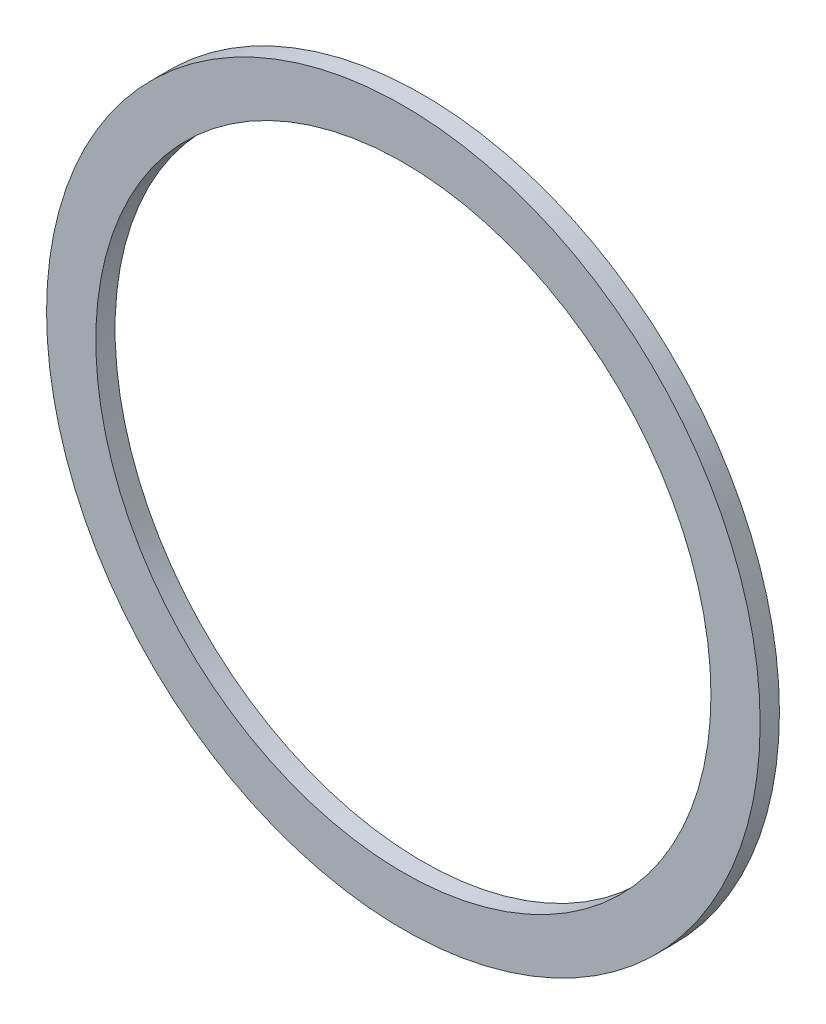
from build123d import *

# Parameters (mm, degrees)
SKETCH1_R           = 87
SKETCH1_R_2         = 75
BOSS_EXTRUDE1_DEPTH = 4.7


with BuildPart() as part:
    # Sketch1 → Boss-Extrude1 (new body)
    with BuildSketch(Plane.XY):
        Circle(SKETCH1_R)
        Circle(SKETCH1_R_2, mode=Mode.SUBTRACT)
    extrude(amount=BOSS_EXTRUDE1_DEPTH)


solid = part.part
